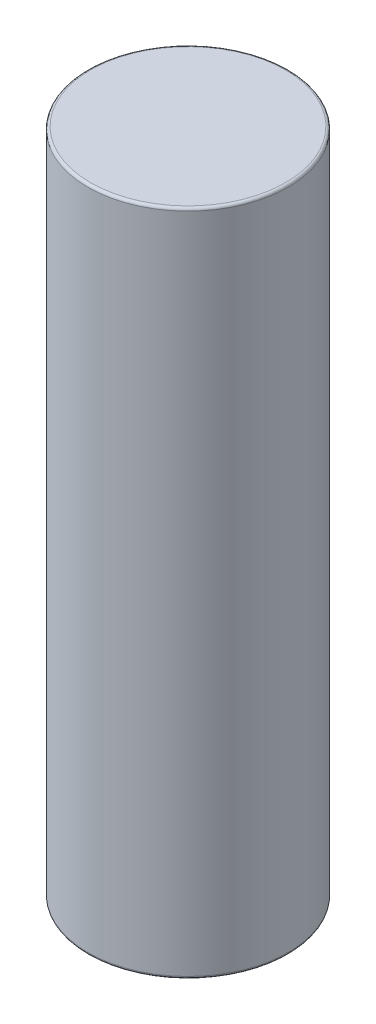
from build123d import *

# Parameters (mm, degrees)
SKETCH1_R           = 15
BOSS_EXTRUDE1_DEPTH = 100
FILLET1_R           = 0.4


with BuildPart() as part:
    # Sketch1 → Boss-Extrude1 (new body)
    with BuildSketch(Plane(origin=(0, 0, 0), x_dir=(1, 0, 0), z_dir=(0, 1, 0))):
        Circle(SKETCH1_R)
    extrude(amount=BOSS_EXTRUDE1_DEPTH)

    # Fillet1
    fillet1_edges = [part.edges().sort_by_distance(p)[0] for p in [
        (-15, 0, 0),
        (-15, 100, 0),
    ]]
    fillet(fillet1_edges, radius=FILLET1_R)


solid = part.part
